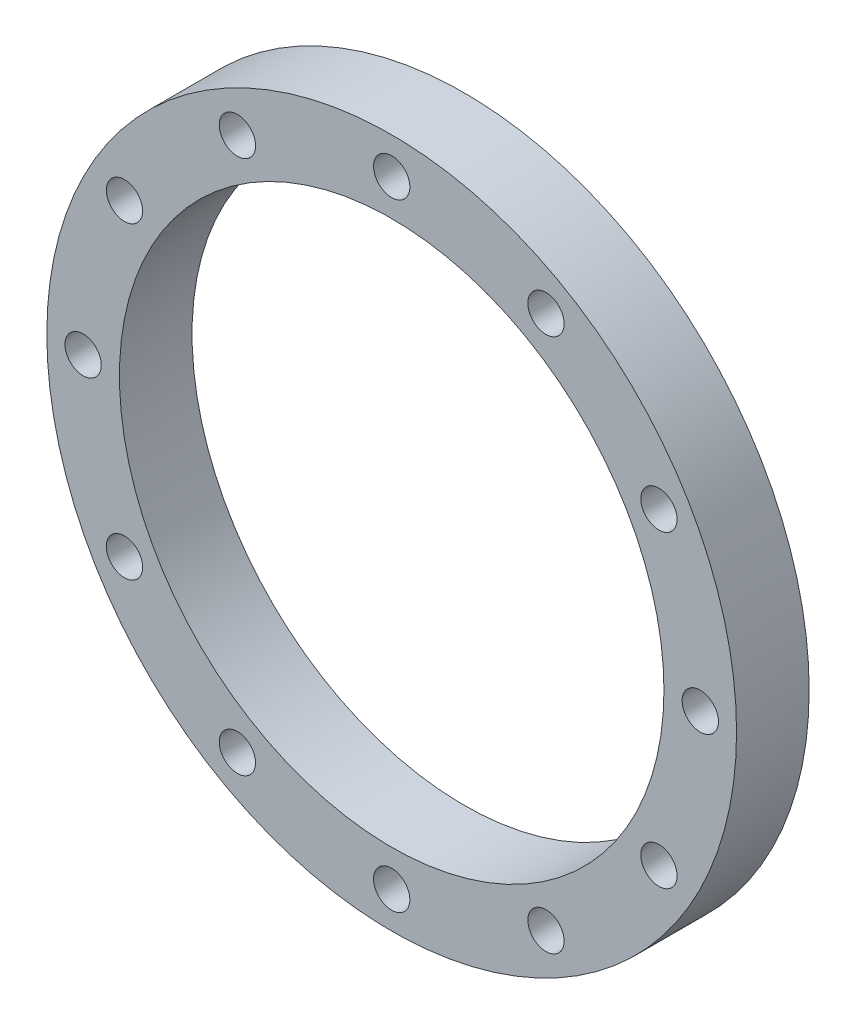
from build123d import *

# Parameters (mm, degrees)
SKETCH1_R              = 241.3
SKETCH1_R_2            = 190.5
BOSS_EXTRUDE1_DEPTH    = 25.4
F_1_1_DIAMETER_HOLE1_D = 25.4
CIRPATTERN1_COUNT      = 12


with BuildPart() as part:
    # Sketch1 → Boss-Extrude1 (new body, symmetric)
    with BuildSketch(Plane.XY):
        Circle(SKETCH1_R)
        Circle(SKETCH1_R_2, mode=Mode.SUBTRACT)
    extrude(amount=BOSS_EXTRUDE1_DEPTH, both=True)

    # 1 (1) Diameter Hole1 (through all)
    with Locations(Plane.XY.offset(25.4)):
        with Locations((215.9, 0)):
            f_1_1_diameter_hole1 = Hole(F_1_1_DIAMETER_HOLE1_D / 2)

    # CirPattern1: 1 (1) Diameter Hole1 ×12 about axis
    cirpattern1_axis = Axis((0, 0, 0), (0, 0, 1))
    for i in range(1, CIRPATTERN1_COUNT):
        add(f_1_1_diameter_hole1.rotate(cirpattern1_axis, i * 360 / CIRPATTERN1_COUNT), mode=Mode.SUBTRACT)


solid = part.part
